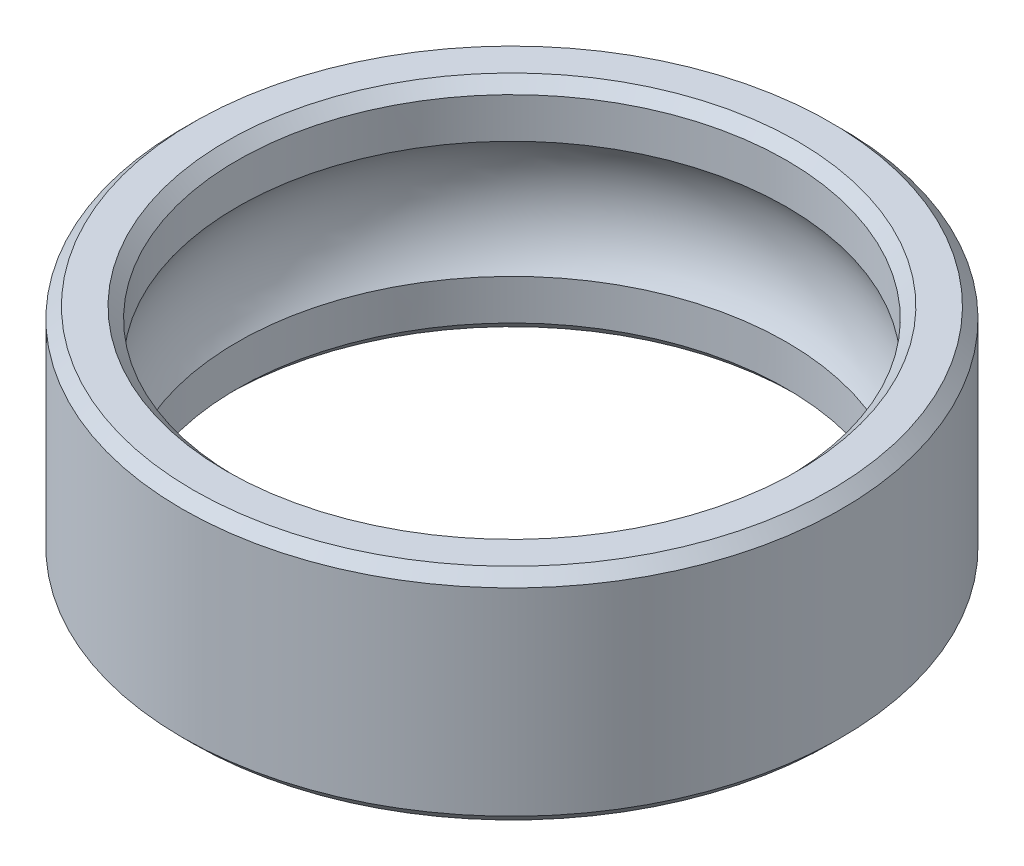
from build123d import *

# Parameters (mm, degrees)
SKETCH1_R           = 6
SKETCH1_R_2         = 5
BOSS_EXTRUDE1_DEPTH = 2
CHAMFER1_SIZE       = 0.2
SKETCH2_R           = 1.8


with BuildPart() as part:
    # Sketch1 → Boss-Extrude1 (new body, symmetric)
    with BuildSketch(Plane(origin=(0, 0, 0), x_dir=(1, 0, 0), z_dir=(0, 1, 0))):
        Circle(SKETCH1_R)
        Circle(SKETCH1_R_2, mode=Mode.SUBTRACT)
    extrude(amount=BOSS_EXTRUDE1_DEPTH, both=True)

    # Chamfer1
    chamfer1_edges = [part.edges().sort_by_distance(p)[0] for p in [
        (-6, -2, 0),
        (-6, 2, 0),
        (-5, -2, 0),
        (-5, 2, 0),
    ]]
    chamfer(chamfer1_edges, length=CHAMFER1_SIZE)

    # Cut-Sweep1: sweep along a path in Sketch3
    with BuildLine(Plane(origin=(0, 0, 0), x_dir=(1, 0, 0), z_dir=(0, 1, 0))) as cut_sweep1_path:
        CenterArc((0, 0), 3.542184236, 0, 360)
    # Sketch2 → Cut-Sweep1 (sweep, cut)
    with BuildSketch(Plane(origin=(0, 0, 0), x_dir=(0, 0, -1), z_dir=(1, 0, 0))):
        with Locations((-3.549093178, 0)):
            Circle(SKETCH2_R)
    sweep(path=cut_sweep1_path.line, mode=Mode.SUBTRACT)


solid = part.part
